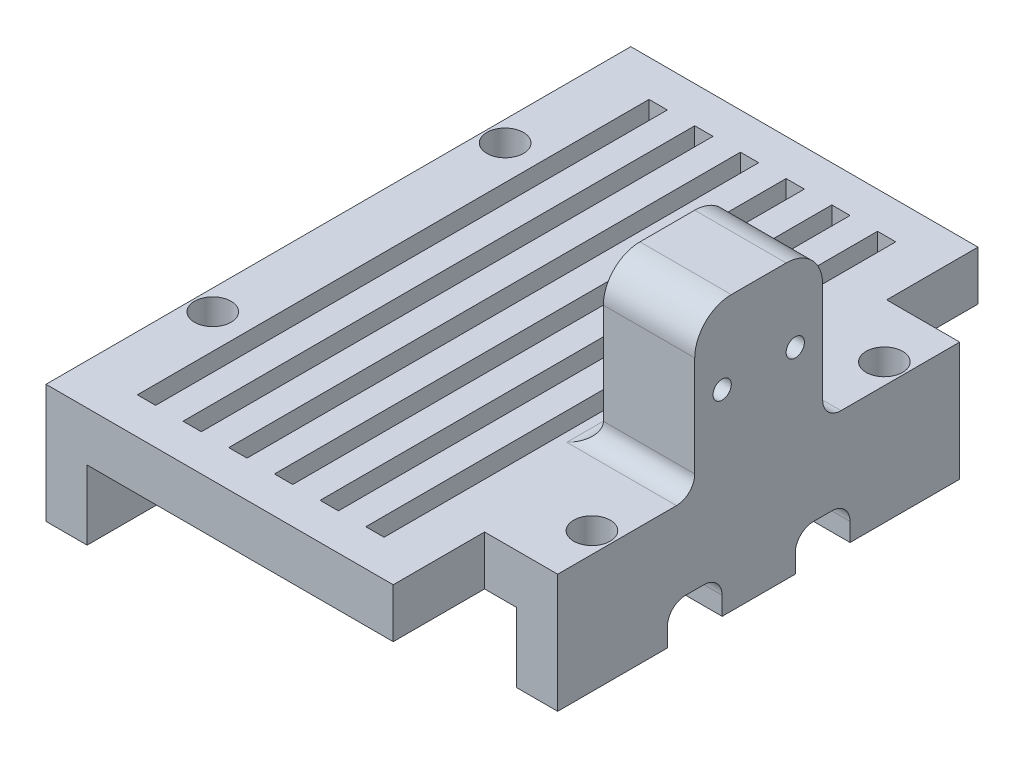
from build123d import *

# Parameters (mm, degrees)
SKETCH_1_W          = 23
SKETCH_1_H          = 32
EXTRUDE_1_DEPTH     = 6.5
SKETCH_3_W          = 18.5
SKETCH_3_H          = 32
CUT_EXTRUDE_1_DEPTH = 3.8
SKETCH_4_W          = 23.00306398
SKETCH_4_H          = 3
CUT_EXTRUDE_2_DEPTH = 2
SKETCH_5_R          = 0.6
CUT_EXTRUDE_3_DEPTH = 7.5
SKETCH_6_W          = 5
SKETCH_6_H          = 7
EXTRUDE_2_DEPTH     = 8.5
FILLET_1_R          = 1
SKETCH_7_R          = 0.5
CUT_EXTRUDE_4_DEPTH = 24
FILLET_2_R          = 2
FILLET_3_R          = 1
SKETCH_8_W          = 4
SKETCH_8_H          = 5
CUT_EXTRUDE_5_DEPTH = 16
SKETCH_9_R          = 1
CUT_EXTRUDE_6_DEPTH = 3
SKETCH_10_W         = 1
SKETCH_10_H         = 28
CUT_EXTRUDE_7_DEPTH = 7.5


with BuildPart() as part:
    # 草图1 → 凸台-拉伸1 (new body)
    with BuildSketch(Plane(origin=(0, 0, 0), x_dir=(1, 0, 0), z_dir=(0, 1, 0))):
        Rectangle(SKETCH_1_W, SKETCH_1_H)
    extrude(amount=EXTRUDE_1_DEPTH)

    # 草图3 → 切除-拉伸1 (cut)
    with BuildSketch(Plane.XZ):
        Rectangle(SKETCH_3_W, SKETCH_3_H)
    extrude(amount=-CUT_EXTRUDE_1_DEPTH, mode=Mode.SUBTRACT)

    # 草图4 → 切除-拉伸2 (cut)
    with BuildSketch(Plane.XZ):
        with Locations((0.00153199, 3.5)):
            Rectangle(SKETCH_4_W, SKETCH_4_H)
        with Locations((0.00153199, -3.5)):
            Rectangle(SKETCH_4_W, SKETCH_4_H)
    extrude(amount=-CUT_EXTRUDE_2_DEPTH, mode=Mode.SUBTRACT)

    # 草图5 → 切除-拉伸3 (cut, through all)
    with BuildSketch(Plane.XZ):
        with Locations((-10.375, -8)):
            Circle(SKETCH_5_R)
        with Locations((10.375, -8)):
            Circle(SKETCH_5_R)
        with Locations((10.375, 8)):
            Circle(SKETCH_5_R)
        with Locations((-10.375, 8)):
            Circle(SKETCH_5_R)
    extrude(amount=-CUT_EXTRUDE_3_DEPTH, mode=Mode.SUBTRACT)

    # 草图6 → 凸台-拉伸2 (add)
    with BuildSketch(Plane(origin=(0, 6.5, 0), x_dir=(1, 0, 0), z_dir=(0, 1, 0))):
        with Locations((9, 0)):
            Rectangle(SKETCH_6_W, SKETCH_6_H)
    extrude(amount=EXTRUDE_2_DEPTH)

    # 圆角1
    fillet_1_edges = [part.edges().sort_by_distance(p)[0] for p in [
        (10.375, 2, 5),
        (-10.375, 2, 5),
        (10.375, 2, 2),
        (-10.375, 2, 2),
        (10.375, 2, -5),
        (-10.375, 2, -5),
        (10.375, 2, -2),
        (-10.375, 2, -2),
    ]]
    fillet(fillet_1_edges, radius=FILLET_1_R)

    # 草图7 → 切除-拉伸4 (cut, through all)
    with BuildSketch(Plane(origin=(11.5, 0, 0), x_dir=(0, 0, -1), z_dir=(1, 0, 0))):
        with Locations((-2, 10.75)):
            Circle(SKETCH_7_R)
        with Locations((2, 10.75)):
            Circle(SKETCH_7_R)
    extrude(amount=-CUT_EXTRUDE_4_DEPTH, mode=Mode.SUBTRACT)

    # 圆角2
    fillet_2_edges = [part.edges().sort_by_distance(p)[0] for p in [
        (9, 15, 3.5),
        (9, 15, -3.5),
    ]]
    fillet(fillet_2_edges, radius=FILLET_2_R)

    # 圆角3
    fillet_3_edges = [part.edges().sort_by_distance(p)[0] for p in [
        (6.5, 6.5, 0),
        (9, 6.5, 3.5),
        (9, 6.5, -3.5),
    ]]
    fillet(fillet_3_edges, radius=FILLET_3_R)

    # 草图8 → 切除-拉伸5 (cut, through all)
    with BuildSketch(Plane.XZ):
        with Locations((9.5, 13.5)):
            Rectangle(SKETCH_8_W, SKETCH_8_H)
        with Locations((9.5, -13.5)):
            Rectangle(SKETCH_8_W, SKETCH_8_H)
    extrude(amount=-CUT_EXTRUDE_5_DEPTH, mode=Mode.SUBTRACT)

    # 草图9 → 切除-拉伸6 (cut)
    with BuildSketch(Plane(origin=(0, 6.5, 0), x_dir=(1, 0, 0), z_dir=(0, 1, 0))):
        with Locations((-10.375, 8)):
            Circle(SKETCH_9_R)
        with Locations((10.375, 8)):
            Circle(SKETCH_9_R)
        with Locations((-10.375, -8)):
            Circle(SKETCH_9_R)
        with Locations((10.375, -8)):
            Circle(SKETCH_9_R)
    extrude(amount=-CUT_EXTRUDE_6_DEPTH, mode=Mode.SUBTRACT)

    # 草图10 → 切除-拉伸7 (cut, through all)
    with BuildSketch(Plane(origin=(0, 6.5, 0), x_dir=(1, 0, 0), z_dir=(0, 1, 0))):
        with Locations((-8, 0)):
            Rectangle(SKETCH_10_W, SKETCH_10_H)
        with Locations((-5.5, 0)):
            Rectangle(SKETCH_10_W, SKETCH_10_H)
        with Locations((-3, 0)):
            Rectangle(SKETCH_10_W, SKETCH_10_H)
        with Locations((-0.5, 0)):
            Rectangle(SKETCH_10_W, SKETCH_10_H)
        with Locations((2, 0)):
            Rectangle(SKETCH_10_W, SKETCH_10_H)
        with Locations((4.5, 0)):
            Rectangle(SKETCH_10_W, SKETCH_10_H)
    extrude(amount=-CUT_EXTRUDE_7_DEPTH, mode=Mode.SUBTRACT)


solid = part.part
